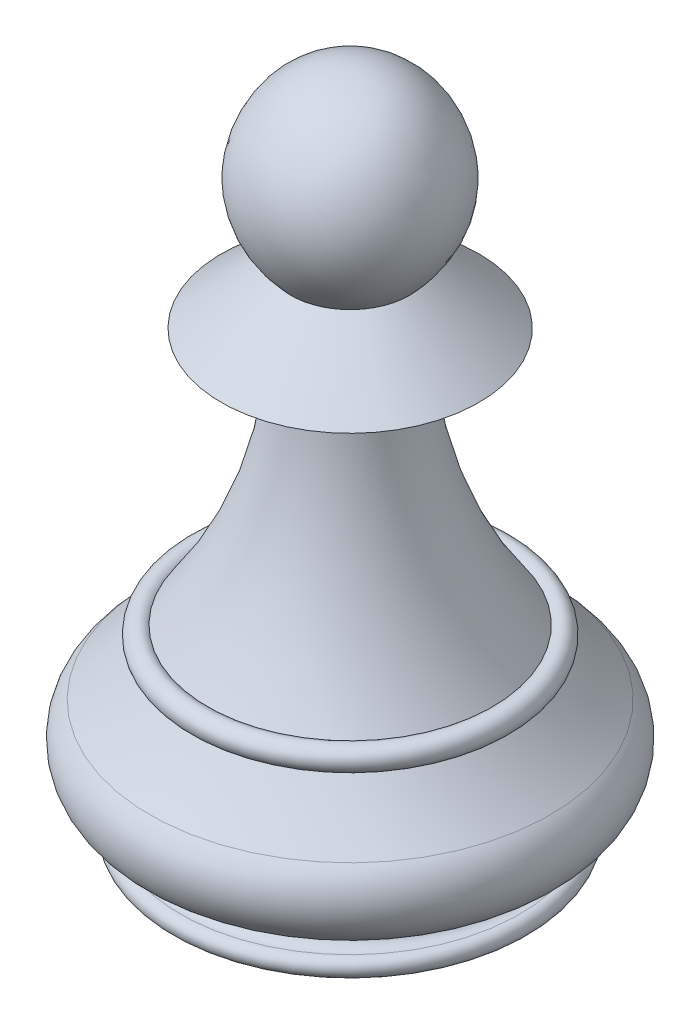
from build123d import *


with BuildPart() as part:
    # Sketch2 → Revolve1 (revolve)
    with BuildSketch(Plane.XY):
        with BuildLine():
            Line((0, 0), (0, 29.42))
            add(Edge.make_bspline(
                [(0, 29.42), (2.453293537, 29.42), (4.980255298, 25.498296392), (3.432674118, 22.909717054), (2.62, 22.053383078)],
                knots=[0, 0, 0, 0, 0.512538121, 1, 1, 1, 1], degree=3))
            Line((2.62, 22.053383078), (5.69725, 19.493383078))
            Line((5.69725, 19.493383078), (2.58725, 19.493383078))
            ThreePointArc((2.58725, 19.493383078), (3.536710579, 13.519210722), (6.291529744, 8.133750473))
            ThreePointArc((6.291529744, 8.133750473), (7.021700209, 8.066812477), (6.9, 7.343750473))
            ThreePointArc((6.9, 7.343750473), (7.836815271, 6.273689057), (8.85, 5.275635456))
            ThreePointArc((8.85, 5.275635456), (9.364305623, 3.075869802), (7.5, 1.8))
            ThreePointArc((7.5, 1.8), (7, 1.3), (7.5, 0.8))
            ThreePointArc((7.5, 0.8), (7.9, 0.4), (7.5, 0))
            Line((7.5, 0), (0, 0))
        make_face()
    revolve(axis=Axis((0, 0, 0), (0, 1, 0)))


solid = part.part
